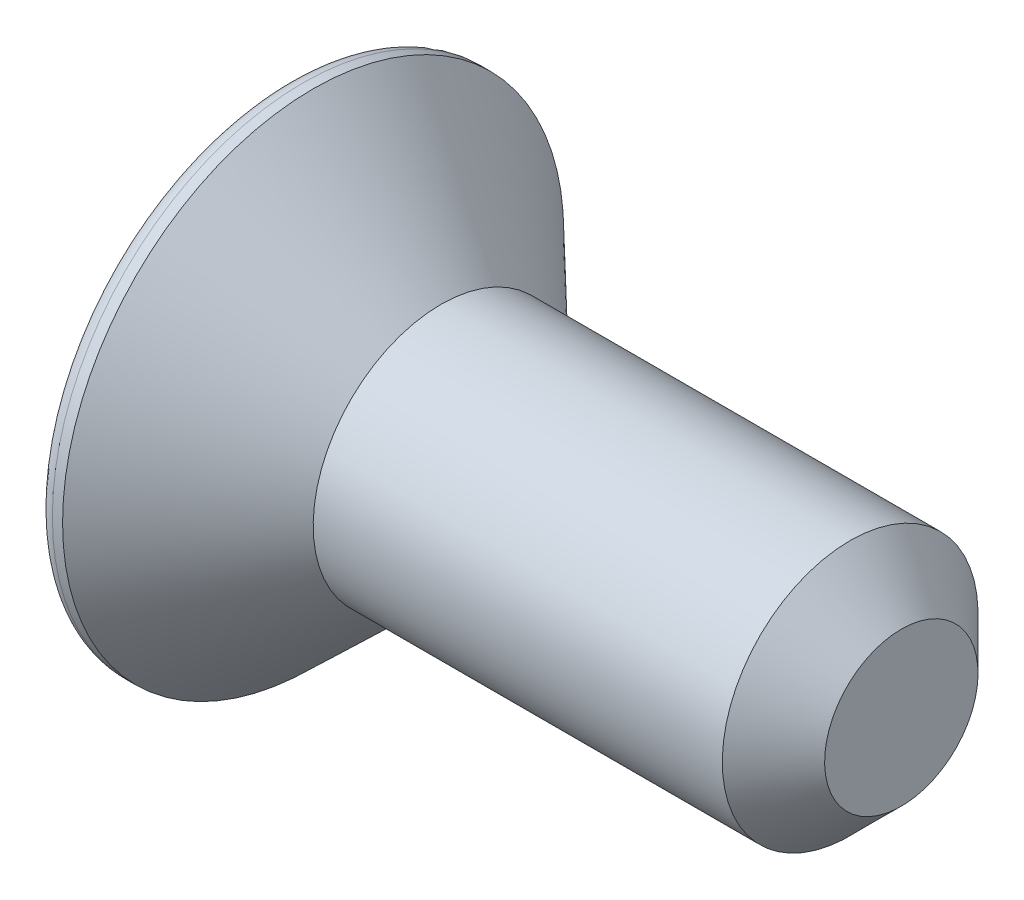
from build123d import *

# Parameters (mm, degrees)
CUT_EXTRUDE_1_DEPTH = 2
FILLET_1_R          = 0.3
CHAMFER_1_SIZE      = 1


with BuildPart() as part:
    # Эскиз1 → Повернуть1 (revolve)
    with BuildSketch(Plane.XY):
        Polygon((0, 0), (0, 4.9), (0.5, 4.9), (3, 2.5), (12, 2.5), (12, 0), align=None)
    revolve(axis=Axis((12, 0, 0), (-1, 0, 0)))

    # Эскиз2 → Вырез-Вытянуть1 (cut)
    with BuildSketch(Plane.ZY):
        Polygon((0.866025404, 1.5), (-0.866025404, 1.5), (-1.732050808, 0), (-0.866025404, -1.5), (0.866025404, -1.5), (1.732050808, 0), align=None)
    extrude(amount=-CUT_EXTRUDE_1_DEPTH, mode=Mode.SUBTRACT)

    # Скругление1
    fillet_1_edges = [part.edges().sort_by_distance(p)[0] for p in [
        (0, -4.9, 0),
    ]]
    fillet(fillet_1_edges, radius=FILLET_1_R)

    # Фаска1
    chamfer_1_edges = [part.edges().sort_by_distance(p)[0] for p in [
        (12, -2.5, 0),
    ]]
    chamfer(chamfer_1_edges, length=CHAMFER_1_SIZE)


solid = part.part
